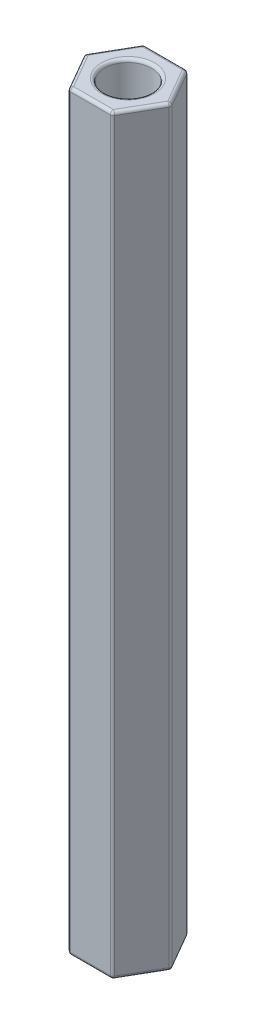
from build123d import *

# Parameters (mm, degrees)
SKETCH1_R           = 1.875
BOSS_EXTRUDE1_DEPTH = 30
FILLET1_R           = 0.25


with BuildPart() as part:
    # Sketch1 → Boss-Extrude1 (new body, symmetric)
    with BuildSketch(Plane(origin=(0, 0, 0), x_dir=(1, 0, 0), z_dir=(0, 1, 0))):
        Polygon((1.732050808, 3), (-1.732050808, 3), (-3.464101615, 0), (-1.732050808, -3), (1.732050808, -3), (3.464101615, 0), align=None)
        Circle(SKETCH1_R, mode=Mode.SUBTRACT)
    extrude(amount=BOSS_EXTRUDE1_DEPTH, both=True)

    # Fillet1
    fillet1_edges = [part.edges().sort_by_distance(p)[0] for p in [
        (-2.598076211, 30, -1.5),
        (3.464101615, 0, 0),
        (1.732050808, 0, 3),
        (-1.732050808, 0, 3),
        (-3.464101615, 0, 0),
        (-1.732050808, 0, -3),
        (1.732050808, 0, -3),
        (-2.598076211, 30, 1.5),
        (0, 30, 3),
        (-1.875, -30, 0),
        (-1.875, 30, 0),
        (2.598076211, 30, 1.5),
        (2.598076211, 30, -1.5),
        (2.598076211, -30, 1.5),
        (0, -30, 3),
        (-2.598076211, -30, 1.5),
        (0, 30, -3),
        (-2.598076211, -30, -1.5),
        (0, -30, -3),
        (2.598076211, -30, -1.5),
    ]]
    fillet(fillet1_edges, radius=FILLET1_R)


solid = part.part
